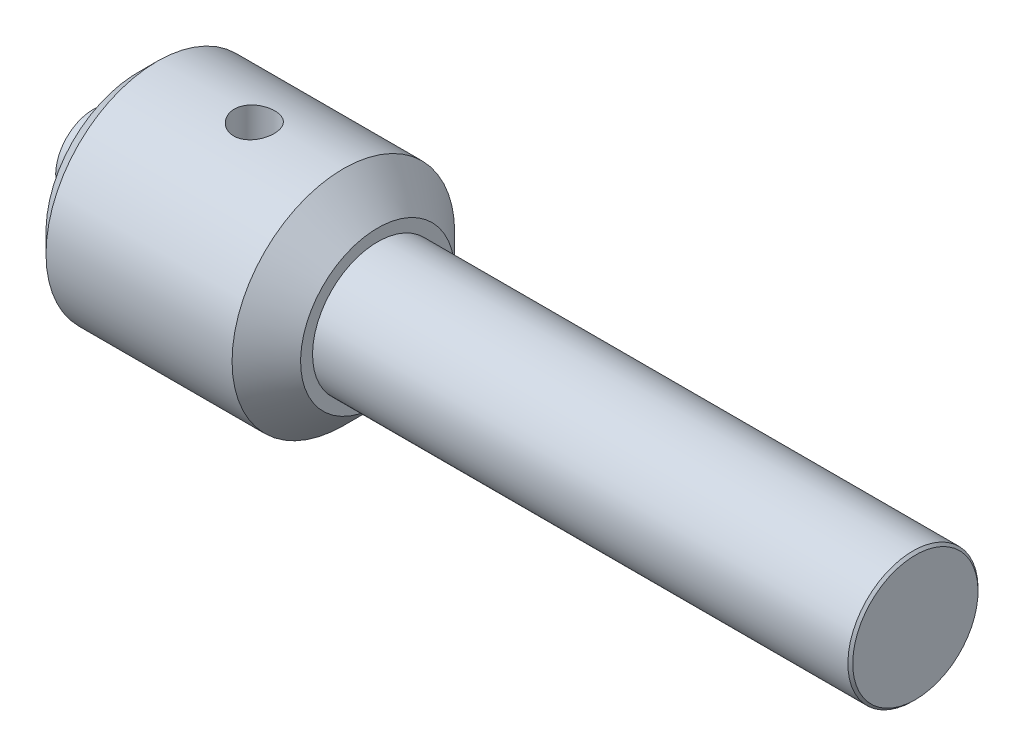
from build123d import *

# Parameters (mm, degrees)
SKETCH2_R               = 6
CUT_EXTRUDE1_DEPTH      = 33.5
CUT_EXTRUDE1_DEPTH_BACK = 33.5
SKETCH3_R               = 6
CUT_EXTRUDE2_DEPTH      = 30
SKETCH5_R               = 5.5
CUT_EXTRUDE4_DEPTH      = 5


with BuildPart() as part:
    # Sketch1 → Revolve2 (revolve)
    with BuildSketch(Plane.XY):
        Polygon((70.405866489, 0), (70.405866489, 18.292893219), (69.698759708, 19), (-86.594133511, 19), (-86.594133511, 22.5), (-96.594133511, 32.5), (-150.920978651, 32.5), (-156.594133511, 26.82684514), (-156.594133511, 11), (-169.594133511, 11), (-169.594133511, 0), align=None)
    revolve(axis=Axis((-169.594133511, 0, 0), (1, 0, 0)))

    # Sketch2 → Cut-Extrude1 (cut, two sides)
    with BuildSketch(Plane(origin=(0, 0, 0), x_dir=(1, 0, 0), z_dir=(0, 1, 0))) as cut_extrude1_sk:
        with Locations((-121.594133511, -1.00894074)):
            Circle(SKETCH2_R)
    extrude(amount=CUT_EXTRUDE1_DEPTH, mode=Mode.SUBTRACT)
    extrude(cut_extrude1_sk.sketch, amount=-CUT_EXTRUDE1_DEPTH_BACK, mode=Mode.SUBTRACT)

    # Sketch3 → Cut-Extrude2 (cut)
    with BuildSketch(Plane.ZY.offset(169.594133511)):
        Circle(SKETCH3_R)
    extrude(amount=-CUT_EXTRUDE2_DEPTH, mode=Mode.SUBTRACT)

    # Sketch5 → Cut-Extrude4 (cut)
    with BuildSketch(Plane.ZY.offset(139.594133511)):
        Circle(SKETCH5_R)
    extrude(amount=-CUT_EXTRUDE4_DEPTH, mode=Mode.SUBTRACT)


solid = part.part
